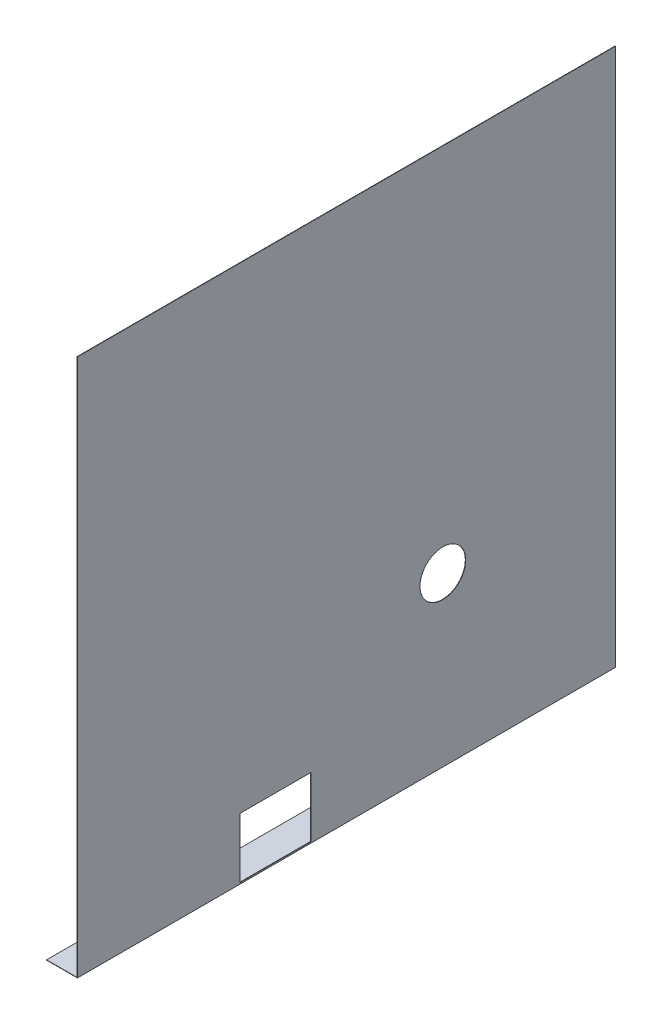
from build123d import *

# Parameters (mm, degrees)
BOSS_EXTRUDE1_DEPTH = 530
SKETCH2_R           = 22.5
CUT_EXTRUDE1_DEPTH  = 530
SKETCH3_W           = 70
SKETCH3_H           = 59
CUT_EXTRUDE2_DEPTH  = 530


with BuildPart() as part:
    # Sketch1 → Boss-Extrude1 (new body)
    with BuildSketch(Plane.XY):
        Polygon((0, 0), (0, 530), (-0.35, 530), (-0.35, 0.35), (-30.35, 0.35), (-30.35, 0), align=None)
    extrude(amount=BOSS_EXTRUDE1_DEPTH)

    # Sketch2 → Cut-Extrude1 (cut)
    with BuildSketch(Plane.ZY.offset(0.35)):
        with Locations((170, 165.35)):
            Circle(SKETCH2_R)
    extrude(amount=-CUT_EXTRUDE1_DEPTH, mode=Mode.SUBTRACT)

    # Sketch3 → Cut-Extrude2 (cut)
    with BuildSketch(Plane.ZY.offset(0.35)):
        with Locations((335, 30.85)):
            Rectangle(SKETCH3_W, SKETCH3_H)
    extrude(amount=-CUT_EXTRUDE2_DEPTH, mode=Mode.SUBTRACT)


solid = part.part
